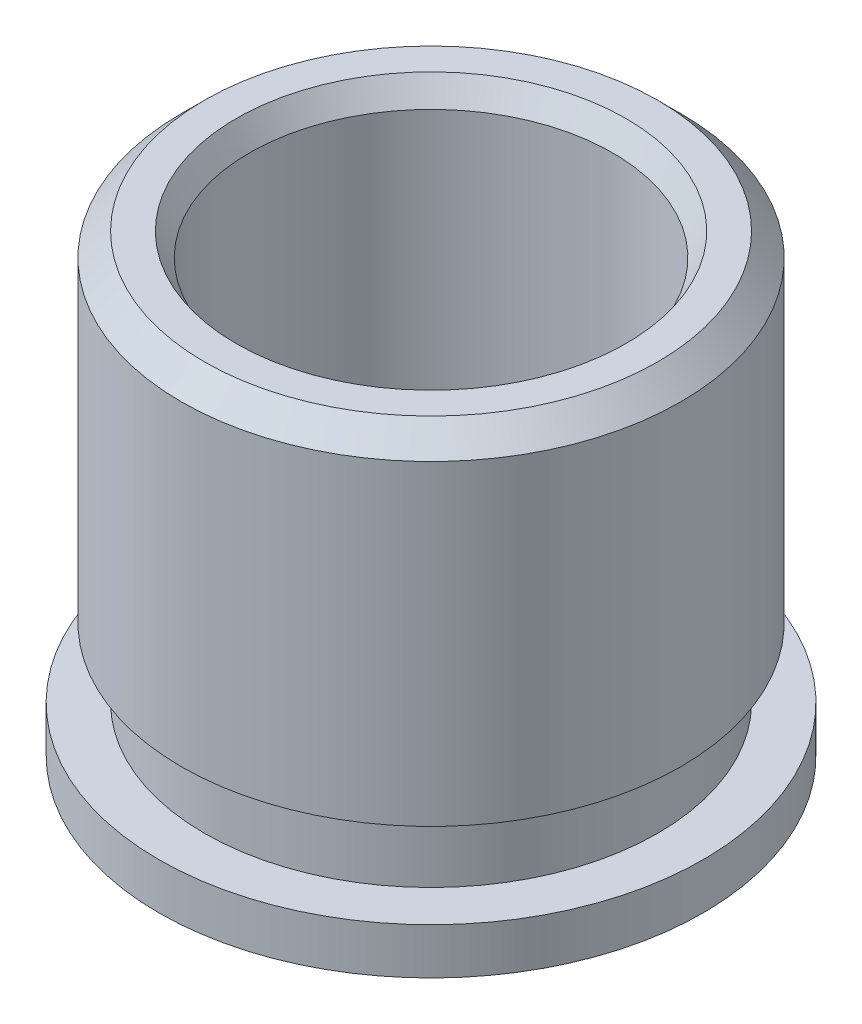
from build123d import *


with BuildPart() as part:
    # Sketch1 → Revolve1 (revolve)
    with BuildSketch(Plane.XY, mode=Mode.PRIVATE) as revolve1_sk:
        Polygon((2.146646968, -2.5019), (2.9972, -2.5019), (2.9972, -1.9939), (2.49555, -1.9939), (2.49555, -1.2319), (2.74955, -1.2319), (2.74955, 2.2479), (2.49555, 2.5019), (2.146646968, 2.5019), (2, 2.2479), (2, -2.2479), align=None)
    revolve(revolve1_sk.sketch.rotate(Axis((0, 2.5019, 0), (0, -1, 0)), 90), axis=Axis((0, 2.5019, 0), (0, -1, 0)))  # turned: the seam where the file's is


solid = part.part
